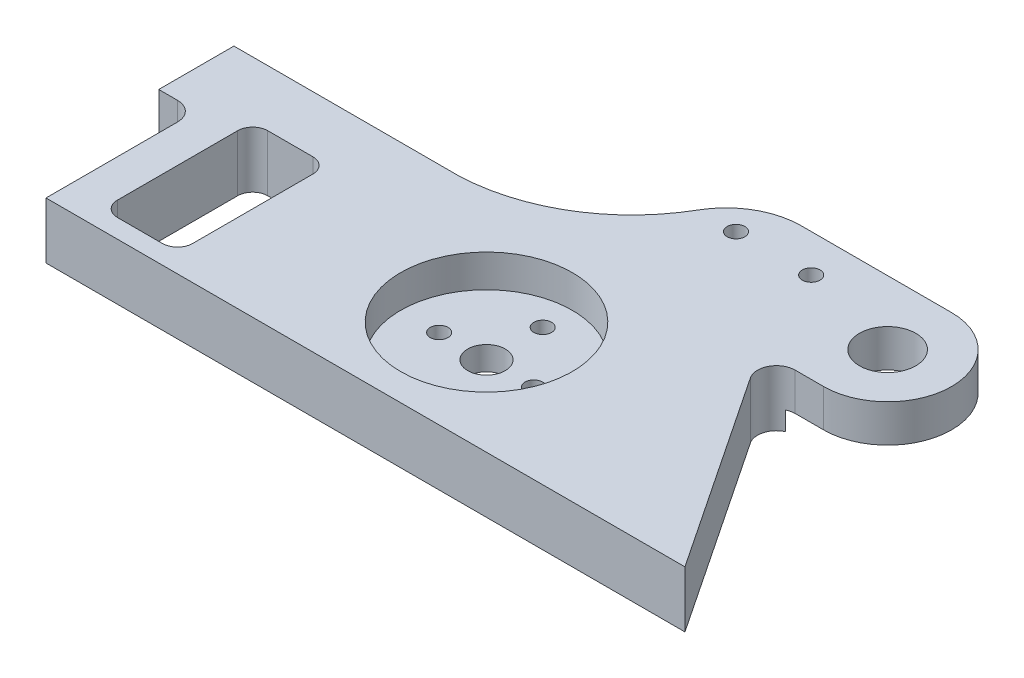
from build123d import *

# Parameters (mm, degrees)
SKETCH1_R           = 4.7625
SKETCH1_R_2         = 1.5
SKETCH1_R_3         = 3.175
BOSS_EXTRUDE1_DEPTH = 9.525
FILLET1_R           = 3.175
FILLET2_R           = 3.175
SKETCH2_R           = 14.5
CUT_EXTRUDE1_DEPTH  = 5.525
SKETCH3_R           = 12.7
CUT_EXTRUDE2_DEPTH  = 3.175
SKETCH4_W           = 12.7
SKETCH4_H           = 25.4
CUT_EXTRUDE3_DEPTH  = 10.525
FILLET3_R           = 2.54


with BuildPart() as part:
    # Sketch1 → Boss-Extrude1 (new body)
    with BuildSketch(Plane(origin=(0, 0, 0), x_dir=(1, 0, 0), z_dir=(0, 1, 0))):
        with BuildLine():
            Line((0, 0), (38.1, 0))
            ThreePointArc((38.1, 0), (52.620300687, 4.403064286), (63.218539249, 15.261399634))
            ThreePointArc((63.218539249, 15.261399634), (67.86863694, 19.924564568), (74.228922018, 21.631986448))
            Line((74.228922018, 21.631986448), (99.628922018, 21.631986448))
            ThreePointArc((99.628922018, 21.631986448), (110.444915242, 10.815993224), (99.628922018, 0))
            Line((99.628922018, 0), (88.9, 0))
            Line((88.9, 0), (114.3, -38.1))
            Line((114.3, -38.1), (6.35, -38.1))
            Line((6.35, -38.1), (6.35, -12.7))
            Line((6.35, -12.7), (0, -12.7))
            Line((0, -12.7), (0, 0))
        make_face()
        with Locations((99.628922018, 10.815993224)):
            Circle(SKETCH1_R, mode=Mode.SUBTRACT)
        with Locations((69.568539249, 15.261399634)):
            Circle(SKETCH1_R_2, mode=Mode.SUBTRACT)
        with Locations((82.268539249, 15.261399634)):
            Circle(SKETCH1_R_2, mode=Mode.SUBTRACT)
        with Locations((69.720479044, -19.05)):
            Circle(SKETCH1_R_2, mode=Mode.SUBTRACT)
        with Locations((61.720479044, -28.55)):
            Circle(SKETCH1_R_2, mode=Mode.SUBTRACT)
        with Locations((53.720479044, -19.05)):
            Circle(SKETCH1_R_2, mode=Mode.SUBTRACT)
        with Locations((61.720479044, -9.55)):
            Circle(SKETCH1_R_2, mode=Mode.SUBTRACT)
        with Locations((61.720479044, -19.05)):
            Circle(SKETCH1_R_3, mode=Mode.SUBTRACT)
    extrude(amount=BOSS_EXTRUDE1_DEPTH)

    # Fillet1
    fillet1_edges = [part.edges().sort_by_distance(p)[0] for p in [
        (88.9, 4.7625, 0),
    ]]
    fillet(fillet1_edges, radius=FILLET1_R)

    # Fillet2
    fillet2_edges = [part.edges().sort_by_distance(p)[0] for p in [
        (6.35, 4.7625, 12.7),
    ]]
    fillet(fillet2_edges, radius=FILLET2_R)

    # Sketch2 → Cut-Extrude1 (cut)
    with BuildSketch(Plane(origin=(0, 9.525, 0), x_dir=(1, 0, 0), z_dir=(0, 1, 0))):
        with Locations((61.720479044, -19.05)):
            Circle(SKETCH2_R)
    extrude(amount=-CUT_EXTRUDE1_DEPTH, mode=Mode.SUBTRACT)

    # Sketch3 → Cut-Extrude2 (cut)
    with BuildSketch(Plane(origin=(0, 0, 0), x_dir=(1, 0, 0), z_dir=(0, 1, 0))):
        with Locations((99.628922018, 10.815993224)):
            Circle(SKETCH3_R)
    extrude(amount=CUT_EXTRUDE2_DEPTH, mode=Mode.SUBTRACT)

    # Sketch4 → Cut-Extrude3 (cut, through all)
    with BuildSketch(Plane.XZ):
        with Locations((19.05, 22.225)):
            Rectangle(SKETCH4_W, SKETCH4_H)
    extrude(amount=-CUT_EXTRUDE3_DEPTH, mode=Mode.SUBTRACT)

    # Fillet3
    fillet3_edges = [part.edges().sort_by_distance(p)[0] for p in [
        (12.7, 4.7625, 34.925),
        (25.4, 4.7625, 34.925),
        (25.4, 4.7625, 9.525),
        (12.7, 4.7625, 9.525),
    ]]
    fillet(fillet3_edges, radius=FILLET3_R)


solid = part.part
